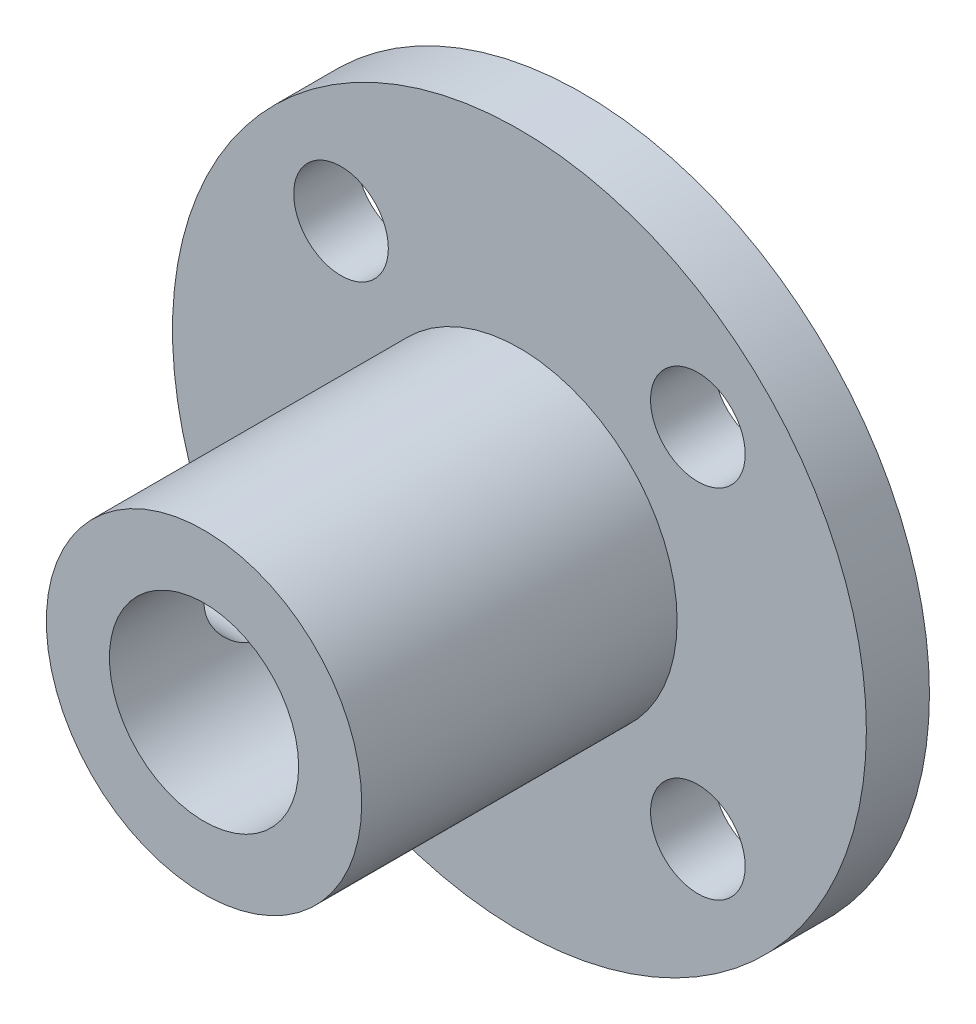
from build123d import *

# Parameters (mm, degrees)
SKETCH_1_R          = 11
EXTRUDE_1_DEPTH     = 2
SKETCH_2_R          = 5
EXTRUDE_2_DEPTH     = 10
SKETCH_3_R          = 3
CUT_EXTRUDE_2_DEPTH = 13
SKETCH_4_R          = 1.5
CUT_EXTRUDE_3_DEPTH = 10
SKETCH_5_R          = 1.5
CUT_EXTRUDE_4_DEPTH = 12


with BuildPart() as part:
    # Эскиз1 → Бобышка-Вытянуть1 (new body)
    with BuildSketch(Plane.XY):
        Circle(SKETCH_1_R)
    extrude(amount=EXTRUDE_1_DEPTH)

    # Эскиз2 → Бобышка-Вытянуть2 (add)
    with BuildSketch(Plane.XY.offset(2)):
        Circle(SKETCH_2_R)
    extrude(amount=EXTRUDE_2_DEPTH)

    # Эскиз3 → Вырез-Вытянуть2 (cut, through all)
    with BuildSketch(Plane.XY):
        Circle(SKETCH_3_R)
    extrude(amount=CUT_EXTRUDE_2_DEPTH, mode=Mode.SUBTRACT)

    # Эскиз4 → Вырез-Вытянуть3 (cut)
    with BuildSketch(Plane.XY.offset(2)):
        with Locations((5.656854249, 5.656854249)):
            Circle(SKETCH_4_R)
        with Locations((5.656854249, -5.656854249)):
            Circle(SKETCH_4_R)
        with Locations((-5.656854249, -5.656854249)):
            Circle(SKETCH_4_R)
        with Locations((-5.656854249, 5.656854249)):
            Circle(SKETCH_4_R)
    extrude(amount=-CUT_EXTRUDE_3_DEPTH, mode=Mode.SUBTRACT)

    # Эскиз5 → Вырез-Вытянуть4 (cut, through all)
    with BuildSketch(Plane(origin=(0, 0, 0), x_dir=(0, 0, -1), z_dir=(1, 0, 0))):
        with Locations((-7.5, 0)):
            Circle(SKETCH_5_R)
    extrude(amount=-CUT_EXTRUDE_4_DEPTH, mode=Mode.SUBTRACT)


solid = part.part
